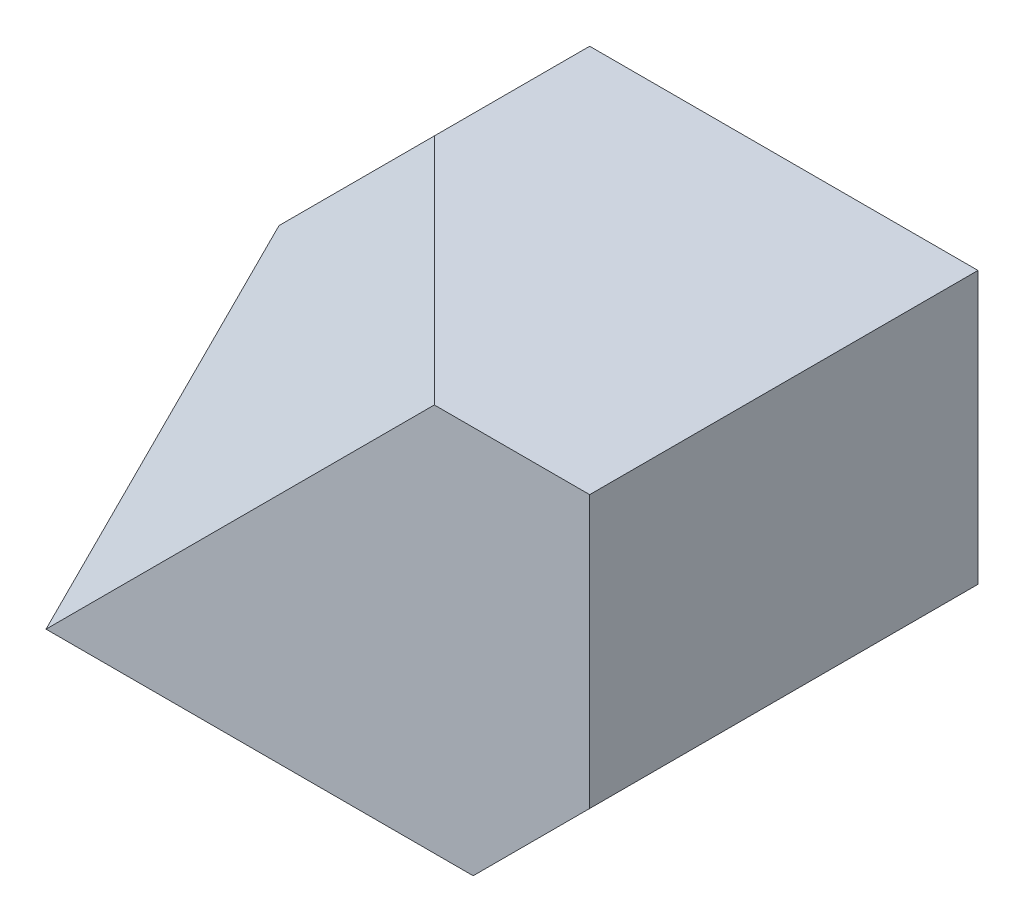
from build123d import *

# Parameters (mm, degrees)
BOSS_EXTRUDE1_DEPTH = 50
CUT_EXTRUDE2_DEPTH  = 30
CUT_EXTRUDE3_DEPTH  = 15
BOSS_EXTRUDE4_DEPTH = 15
BOSS_EXTRUDE6_DEPTH = 52
BOSS_EXTRUDE7_DEPTH = 52
CUT_EXTRUDE6_DEPTH  = 52
BOSS_EXTRUDE8_DEPTH = 30
BOSS_EXTRUDE9_DEPTH = 15
CUT_EXTRUDE7_DEPTH  = 15
CUT_EXTRUDE8_DEPTH  = 15


with BuildPart() as part:
    # Sketch1 → Boss-Extrude1 (new body)
    with BuildSketch(Plane.XY):
        Polygon((0, 0), (0, 30), (20, 50), (70, 50), (70, 15), (55, 0), align=None)
    extrude(amount=BOSS_EXTRUDE1_DEPTH)

    # Sketch2 → Cut-Extrude2 (cut)
    with BuildSketch(Plane.XY.offset(50)):
        Polygon((0, 0), (50, 50), (20, 50), (0, 30), align=None)
    extrude(amount=-CUT_EXTRUDE2_DEPTH, mode=Mode.SUBTRACT)

    # Sketch4 → Cut-Extrude3 (cut)
    with BuildSketch(Plane(origin=(0, 0, 0), x_dir=(-1, 0, 0), z_dir=(0, 0, -1))):
        Polygon((-70, 15), (-55, 15), (-55, 0), align=None)
    extrude(amount=-CUT_EXTRUDE3_DEPTH, mode=Mode.SUBTRACT)

    # Sketch7 → Boss-Extrude4 (add)
    with BuildSketch(Plane(origin=(13.333333333, -13.333333333, -13.333333333), x_dir=(-0.816496581, -0.40824829, -0.40824829), z_dir=(0.577350269, -0.577350269, -0.577350269))):
        Polygon((-51.031036308, -10.606601718), (-69.402209379, 0), (-51.031036308, 10.606601718), align=None)
    extrude(amount=-BOSS_EXTRUDE4_DEPTH)

    # Sketch11 → Boss-Extrude6 (add)
    with BuildSketch(Plane.ZY):
        Polygon((20, 30), (50, 0), (20, 0), align=None)
    extrude(amount=-BOSS_EXTRUDE6_DEPTH)

    # Sketch12 → Boss-Extrude7 (add)
    with BuildSketch(Plane(origin=(0, 50, 0), x_dir=(1, 0, 0), z_dir=(0, 1, 0))):
        Polygon((20, -20), (50, -50), (50, -20), align=None)
    extrude(amount=-BOSS_EXTRUDE7_DEPTH)

    # Sketch13 → Cut-Extrude6 (cut)
    with BuildSketch(Plane.XZ):
        Polygon((20, 20), (50, 20), (50, 50), align=None)
    extrude(amount=CUT_EXTRUDE6_DEPTH, mode=Mode.SUBTRACT)

    # Sketch14 → Boss-Extrude8 (add)
    with BuildSketch(Plane(origin=(-16.666666667, 16.666666667, 16.666666667), x_dir=(-0.816496581, -0.40824829, -0.40824829), z_dir=(0.577350269, -0.577350269, -0.577350269))):
        Polygon((-20.412414523, 7.071067812), (-44.907311951, 21.213203436), (-81.649658093, 0), align=None)
    extrude(amount=BOSS_EXTRUDE8_DEPTH)

    # Sketch15 → Boss-Extrude9 (add)
    with BuildSketch(Plane(origin=(-16.666666667, 16.666666667, 16.666666667), x_dir=(0.816496581, 0.40824829, 0.40824829), z_dir=(-0.577350269, 0.577350269, 0.577350269))):
        Polygon((20.412414523, -35.355339059), (81.649658093, 0), (20.412414523, 7.071067812), align=None)
    extrude(amount=-BOSS_EXTRUDE9_DEPTH)

    # Sketch16 → Cut-Extrude7 (cut)
    with BuildSketch(Plane.XZ):
        Polygon((0, 50), (8.660254038, 32.679491924), (17.320508076, 41.339745962), align=None)
    extrude(amount=CUT_EXTRUDE7_DEPTH, mode=Mode.SUBTRACT)

    # Sketch17 → Cut-Extrude8 (cut)
    with BuildSketch(Plane(origin=(0, 0, 0), x_dir=(-1, 0, 0), z_dir=(0, -1, 0))):
        Polygon((0, 0), (-20, -20), (-20, 0), align=None)
    extrude(amount=-CUT_EXTRUDE8_DEPTH, mode=Mode.SUBTRACT)


solid = part.part
